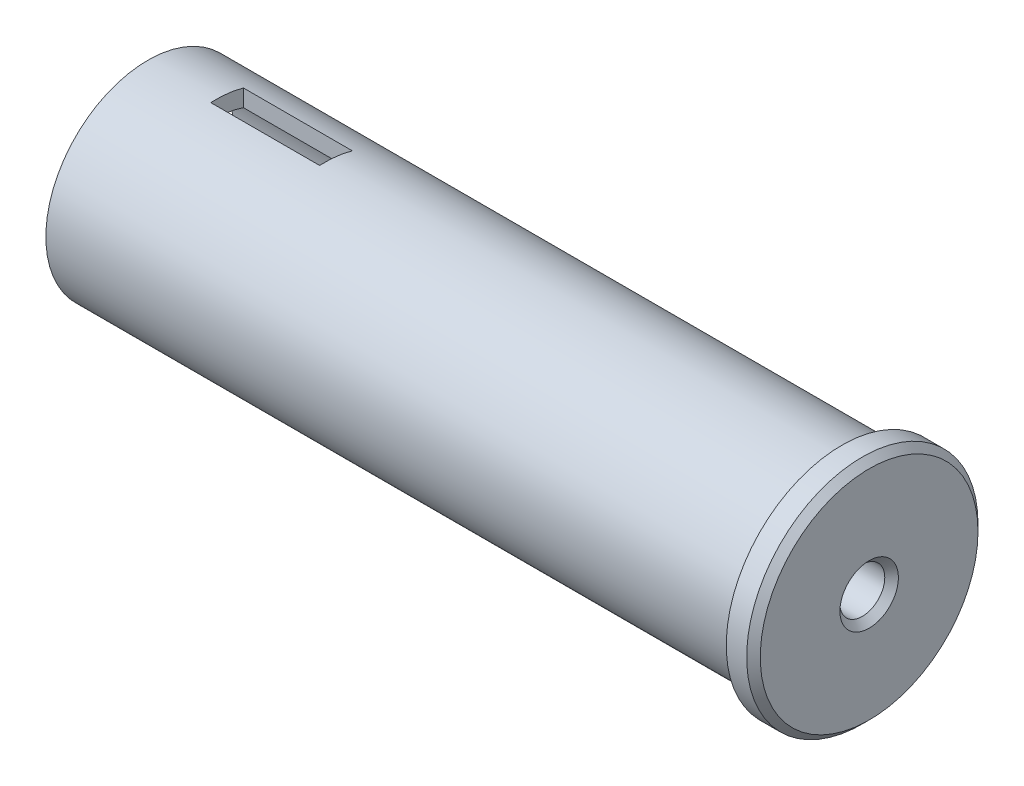
from build123d import *

# Parameters (mm, degrees)
CHAMFER2_SIZE           = 0.5
SKETCH3_W               = 8
SKETCH3_H               = 2.4
CUT_EXTRUDE1_DEPTH      = 9.5
CUT_EXTRUDE1_DEPTH_BACK = 9.5


with BuildPart() as part:
    # Sketch2 → Revolve1 (revolve)
    with BuildSketch(Plane(origin=(0, 0, 0), x_dir=(1, 0, 0), z_dir=(0, 1, 0))):
        Polygon((0, 1.65), (-11, 1.65), (-11, 6.3), (-53, 6.3), (-53, 7.5), (-2, 7.5), (-2, 8.5), (0, 8.5), align=None)
    revolve(axis=Axis((0, 0, 0), (-1, 0, 0)))

    # Chamfer2
    chamfer2_edges = [part.edges().sort_by_distance(p)[0] for p in [
        (0, 0, 8.5),
        (0, 0, 1.65),
    ]]
    chamfer(chamfer2_edges, length=CHAMFER2_SIZE)

    # Sketch3 → Cut-Extrude1 (cut, two sides)
    with BuildSketch(Plane(origin=(0, 0, 0), x_dir=(1, 0, 0), z_dir=(0, 1, 0))) as cut_extrude1_sk:
        with Locations((-44, 0.817065344)):
            Rectangle(SKETCH3_W, SKETCH3_H)
    extrude(amount=CUT_EXTRUDE1_DEPTH, mode=Mode.SUBTRACT)
    extrude(cut_extrude1_sk.sketch, amount=-CUT_EXTRUDE1_DEPTH_BACK, mode=Mode.SUBTRACT)


solid = part.part
